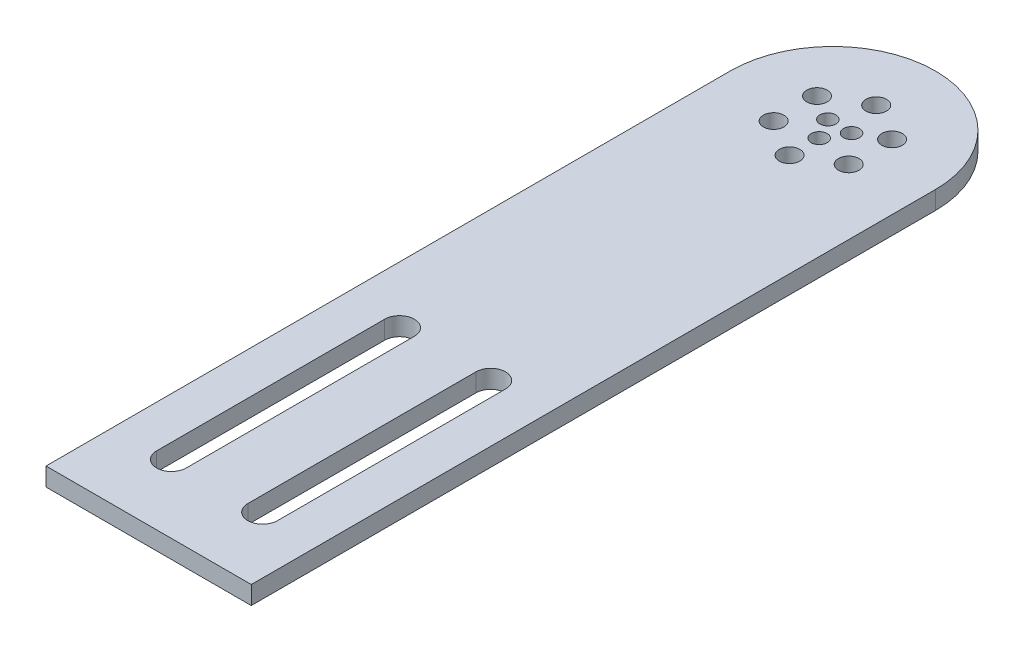
from build123d import *

# Parameters (mm, degrees)
SKETCH1_W           = 45
SKETCH1_H           = 150
BOSS_EXTRUDE1_DEPTH = 4
SKETCH2_R           = 22.5
BOSS_EXTRUDE2_DEPTH = 4
SKETCH3_R           = 2.25
CUT_EXTRUDE1_DEPTH  = 5
CIRPATTERN1_COUNT   = 6
SKETCH4_R           = 1.75
CUT_EXTRUDE2_DEPTH  = 4
CIRPATTERN2_COUNT   = 3
CUT_EXTRUDE3_DEPTH  = 4


with BuildPart() as part:
    # Sketch1 → Boss-Extrude1 (new body)
    with BuildSketch(Plane(origin=(0, 0, 0), x_dir=(1, 0, 0), z_dir=(0, 1, 0))):
        Rectangle(SKETCH1_W, SKETCH1_H)
    extrude(amount=BOSS_EXTRUDE1_DEPTH)

    # Sketch2 → Boss-Extrude2 (add)
    with BuildSketch(Plane(origin=(0, 0, 0), x_dir=(1, 0, 0), z_dir=(0, 1, 0))):
        with Locations((0, 75)):
            Circle(SKETCH2_R)
    extrude(amount=BOSS_EXTRUDE2_DEPTH)

    # Sketch3 → Cut-Extrude1 (cut, through all)
    with BuildSketch(Plane(origin=(0, 4, 0), x_dir=(1, 0, 0), z_dir=(0, 1, 0))):
        with Locations((0, 84.5)):
            Circle(SKETCH3_R)
    cut_extrude1 = extrude(amount=-CUT_EXTRUDE1_DEPTH, mode=Mode.SUBTRACT)

    # CirPattern1: Cut-Extrude1 ×6 about axis
    cirpattern1_axis = Axis((0, 0, -75), (0, 1, 0))
    for i in range(1, CIRPATTERN1_COUNT):
        add(cut_extrude1.rotate(cirpattern1_axis, i * 360 / CIRPATTERN1_COUNT), mode=Mode.SUBTRACT)

    # Sketch4 → Cut-Extrude2 (cut)
    with BuildSketch(Plane(origin=(0, 4, 0), x_dir=(1, 0, 0), z_dir=(0, 1, 0))):
        with Locations((0, 72)):
            Circle(SKETCH4_R)
    cut_extrude2 = extrude(amount=-CUT_EXTRUDE2_DEPTH, mode=Mode.SUBTRACT)

    # CirPattern2: Cut-Extrude2 ×3 about axis
    cirpattern2_axis = Axis((0, 0, -75), (0, 1, 0))
    for i in range(1, CIRPATTERN2_COUNT):
        add(cut_extrude2.rotate(cirpattern2_axis, i * 360 / CIRPATTERN2_COUNT), mode=Mode.SUBTRACT)

    # Sketch5 → Cut-Extrude3 (cut)
    with BuildSketch(Plane(origin=(0, 4, 0), x_dir=(1, 0, 0), z_dir=(0, 1, 0))):
        with BuildLine():
            Line((-6.75, -10), (-6.75, -60))
            ThreePointArc((-6.75, -60), (-10, -63.25), (-13.25, -60))
            Line((-13.25, -60), (-13.25, -10))
            ThreePointArc((-13.25, -10), (-10, -6.75), (-6.75, -10))
        make_face()
    cut_extrude3 = extrude(amount=-CUT_EXTRUDE3_DEPTH, mode=Mode.SUBTRACT)

    # Mirror1: Cut-Extrude3 across plane
    add(cut_extrude3.mirror(Plane(origin=(0, 0, 0), x_dir=(0, 0, 1), z_dir=(1, 0, 0))), mode=Mode.SUBTRACT)


solid = part.part
